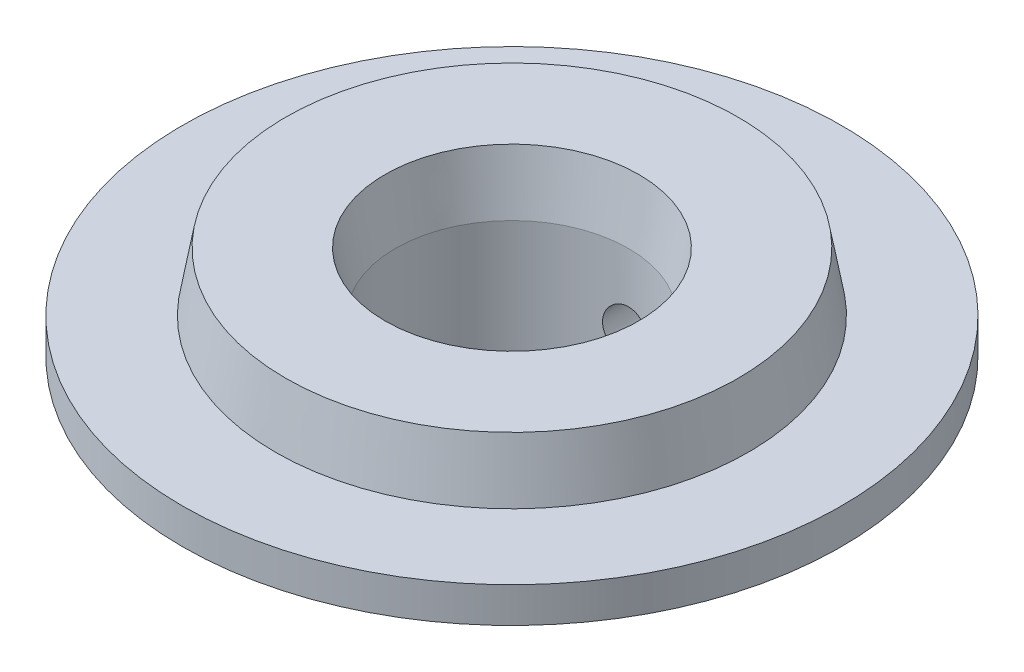
from build123d import *

# Parameters (mm, degrees)
SKETCH1_R               = 14
SKETCH1_R_2             = 9.9
BOSS_EXTRUDE1_DEPTH     = 7
SKETCH2_R               = 28
SKETCH2_R_2             = 9.9
BOSS_EXTRUDE2_DEPTH     = 3
SKETCH3_R               = 20.1
SKETCH3_R_2             = 9.9
BOSS_EXTRUDE3_DEPTH     = 5
BOSS_EXTRUDE3_TAPER     = 10
SKETCH4_R               = 2
CUT_EXTRUDE1_DEPTH      = 19
CUT_EXTRUDE1_DEPTH_BACK = 39


with BuildPart() as part:
    # Sketch1 → Boss-Extrude1 (new body)
    with BuildSketch(Plane(origin=(0, 0, 0), x_dir=(1, 0, 0), z_dir=(0, 1, 0))):
        Circle(SKETCH1_R)
        Circle(SKETCH1_R_2, mode=Mode.SUBTRACT)
    extrude(amount=BOSS_EXTRUDE1_DEPTH)

    # Sketch2 → Boss-Extrude2 (add)
    with BuildSketch(Plane(origin=(0, 7, 0), x_dir=(1, 0, 0), z_dir=(0, 1, 0))):
        Circle(SKETCH2_R)
        Circle(SKETCH2_R_2, mode=Mode.SUBTRACT)
    extrude(amount=BOSS_EXTRUDE2_DEPTH)

    # Sketch4 → Cut-Extrude1 (cut, two sides)
    with BuildSketch(Plane.XY.offset(10)) as cut_extrude1_sk:
        with Locations((0, 3.704215295)):
            Circle(SKETCH4_R)
    extrude(amount=CUT_EXTRUDE1_DEPTH, mode=Mode.SUBTRACT)
    extrude(cut_extrude1_sk.sketch, amount=-CUT_EXTRUDE1_DEPTH_BACK, mode=Mode.SUBTRACT)


with BuildPart() as body_2:
    # Sketch3 → Boss-Extrude3 (new body)
    with BuildSketch(Plane(origin=(0, 10, 0), x_dir=(1, 0, 0), z_dir=(0, 1, 0))):
        Circle(SKETCH3_R)
        Circle(SKETCH3_R_2, mode=Mode.SUBTRACT)
    extrude(amount=BOSS_EXTRUDE3_DEPTH, taper=BOSS_EXTRUDE3_TAPER)


solid = Compound([part.part, body_2.part])
